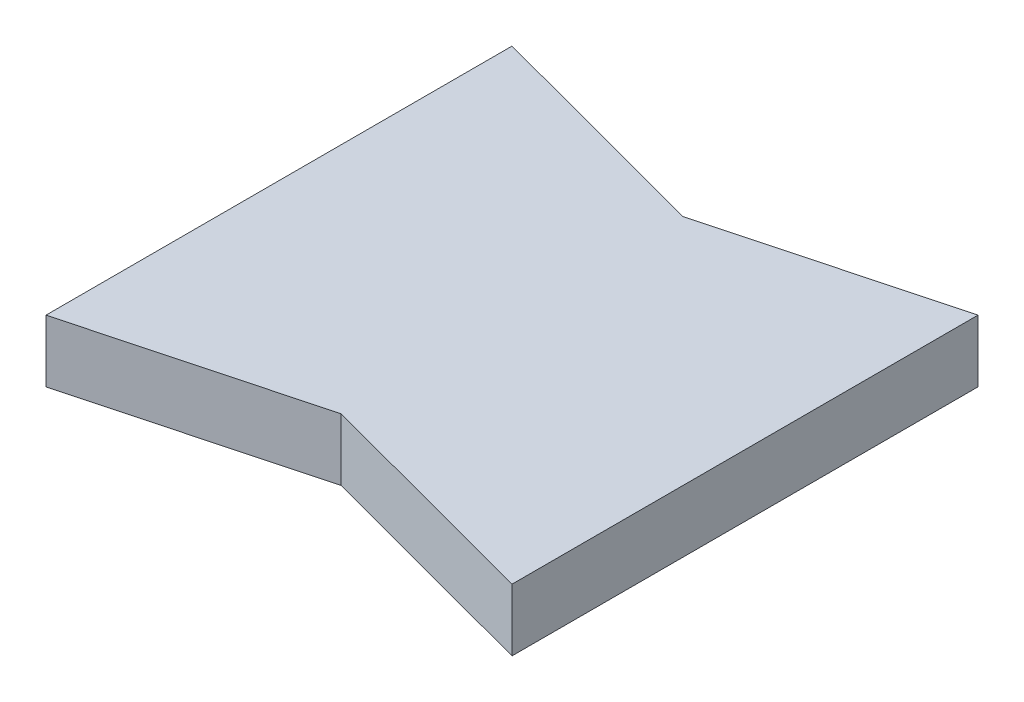
from build123d import *

# Parameters (mm, degrees)
BOSS_EXTRUDE2_DEPTH = 4


with BuildPart() as part:
    # Sketch1 → Boss-Extrude2 (new body)
    with BuildSketch(Plane(origin=(0, 0, 0), x_dir=(1, 0, 0), z_dir=(0, 1, 0))):
        Polygon((-33.992673993, 12.124542125), (-18.992673993, 8.124542125), (-3.992673993, 12.124542125), (-3.992673993, -17.875457875), (-18.992673993, -13.875457875), (-33.992673993, -17.875457875), align=None)
    extrude(amount=BOSS_EXTRUDE2_DEPTH)


solid = part.part
